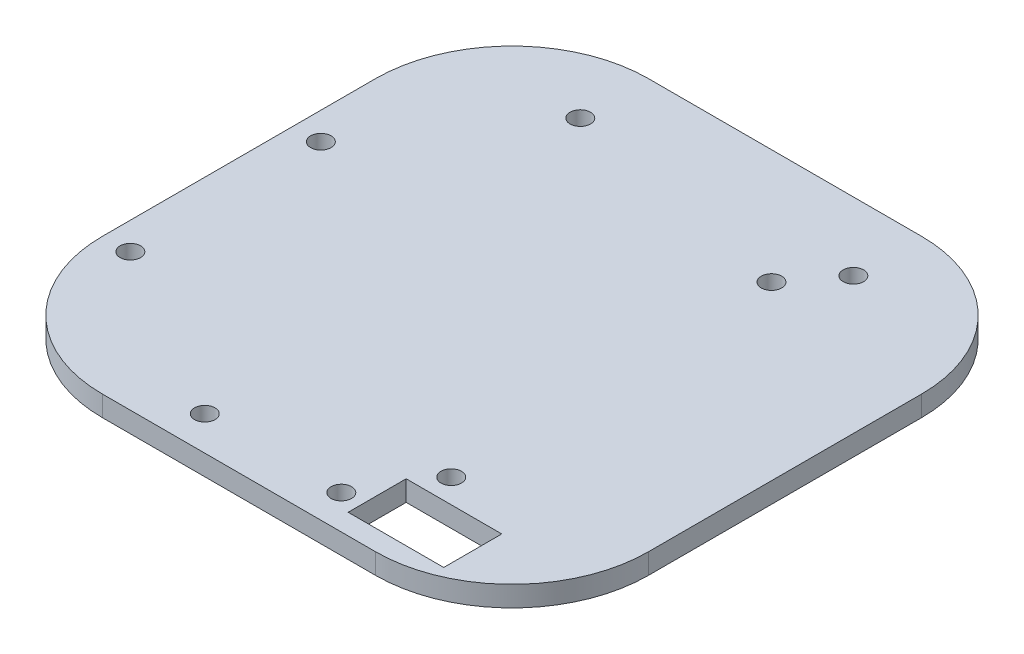
from build123d import *

# Parameters (mm, degrees)
SKETCH3_W           = 80
SKETCH3_H           = 80
BOSS_EXTRUDE1_DEPTH = 3
FILLET3_R           = 20
FILLET4_R           = 20
FILLET5_R           = 20
FILLET6_R           = 20
SKETCH12_R          = 1.5
CUT_EXTRUDE6_DEPTH  = 3
SKETCH13_R          = 1.5
CUT_EXTRUDE7_DEPTH  = 3
SKETCH14_R          = 1.5
CUT_EXTRUDE8_DEPTH  = 10
SKETCH15_W          = 14
SKETCH15_H          = 8.5
CUT_EXTRUDE9_DEPTH  = 10


with BuildPart() as part:
    # Sketch3 → Boss-Extrude1 (new body)
    with BuildSketch(Plane(origin=(0, 0, 0), x_dir=(1, 0, 0), z_dir=(0, 1, 0))):
        with Locations((40, 40)):
            Rectangle(SKETCH3_W, SKETCH3_H)
    extrude(amount=BOSS_EXTRUDE1_DEPTH)

    # Fillet3
    fillet3_edges = [part.edges().sort_by_distance(p)[0] for p in [
        (0, 1.5, -80),
    ]]
    fillet(fillet3_edges, radius=FILLET3_R)

    # Fillet4
    fillet4_edges = [part.edges().sort_by_distance(p)[0] for p in [
        (80, 1.5, -80),
    ]]
    fillet(fillet4_edges, radius=FILLET4_R)

    # Fillet5
    fillet5_edges = [part.edges().sort_by_distance(p)[0] for p in [
        (80, 1.5, 0),
    ]]
    fillet(fillet5_edges, radius=FILLET5_R)

    # Fillet6
    fillet6_edges = [part.edges().sort_by_distance(p)[0] for p in [
        (0, 1.5, 0),
    ]]
    fillet(fillet6_edges, radius=FILLET6_R)

    # Sketch12 → Cut-Extrude6 (cut)
    with BuildSketch(Plane(origin=(0, 3, 0), x_dir=(1, 0, 0), z_dir=(0, 1, 0))):
        with Locations((30, 5)):
            Circle(SKETCH12_R)
        with Locations((50, 5)):
            Circle(SKETCH12_R)
    extrude(amount=-CUT_EXTRUDE6_DEPTH, mode=Mode.SUBTRACT)

    # Sketch13 → Cut-Extrude7 (cut)
    with BuildSketch(Plane(origin=(0, 3, 0), x_dir=(1, 0, 0), z_dir=(0, 1, 0))):
        with Locations((20, 70)):
            Circle(SKETCH13_R)
        with Locations((60, 70)):
            Circle(SKETCH13_R)
    extrude(amount=-CUT_EXTRUDE7_DEPTH, mode=Mode.SUBTRACT)

    # Sketch14 → Cut-Extrude8 (cut)
    with BuildSketch(Plane(origin=(0, 3, 0), x_dir=(1, 0, 0), z_dir=(0, 1, 0))):
        with Locations((4, 20.1)):
            Circle(SKETCH14_R)
        with Locations((4, 48)):
            Circle(SKETCH14_R)
        with Locations((54.8, 63.2)):
            Circle(SKETCH14_R)
        with Locations((56.1, 15)):
            Circle(SKETCH14_R)
    extrude(amount=-CUT_EXTRUDE8_DEPTH, mode=Mode.SUBTRACT)

    # Sketch15 → Cut-Extrude9 (cut)
    with BuildSketch(Plane(origin=(0, 3, 0), x_dir=(1, 0, 0), z_dir=(0, 1, 0))):
        with Locations((60, 7.25)):
            Rectangle(SKETCH15_W, SKETCH15_H)
    extrude(amount=-CUT_EXTRUDE9_DEPTH, mode=Mode.SUBTRACT)


solid = part.part
